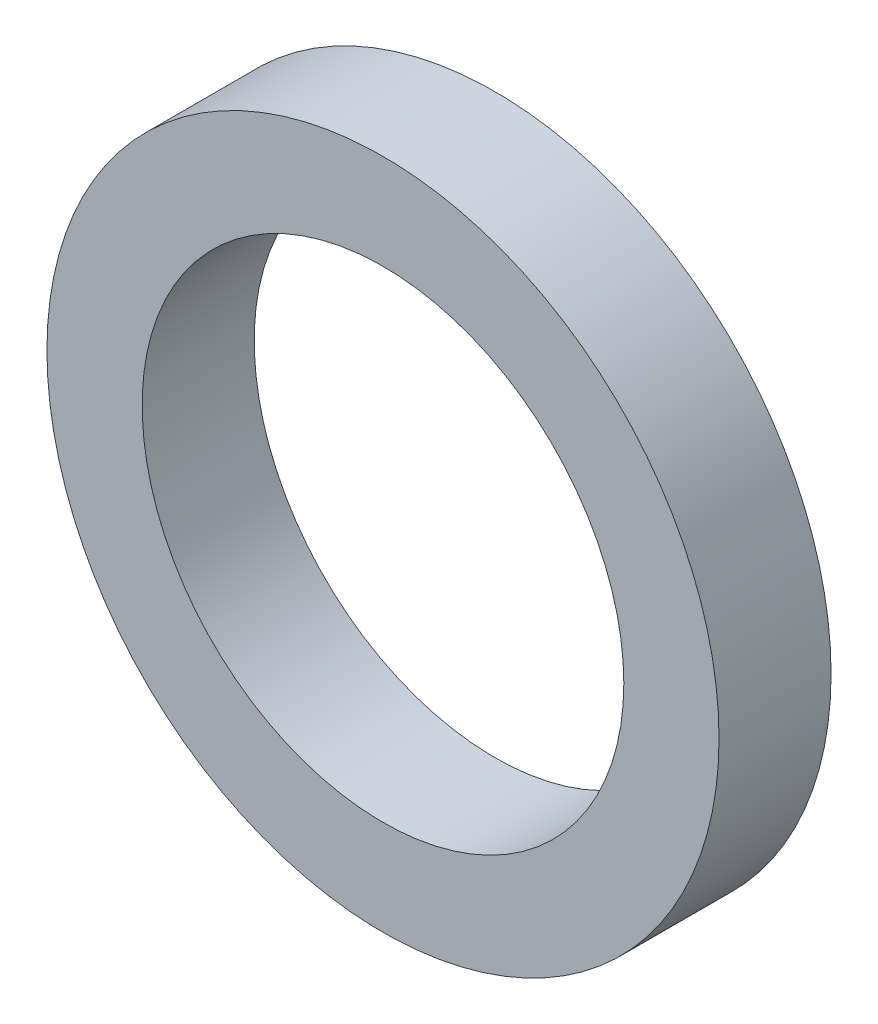
from build123d import *

# Parameters (mm, degrees)
SKETCH1_R           = 3
SKETCH1_R_2         = 2.15
BOSS_EXTRUDE1_DEPTH = 1


with BuildPart() as part:
    # Sketch1 → Boss-Extrude1 (new body)
    with BuildSketch(Plane.XY):
        Circle(SKETCH1_R)
        Circle(SKETCH1_R_2, mode=Mode.SUBTRACT)
    extrude(amount=BOSS_EXTRUDE1_DEPTH)


solid = part.part
